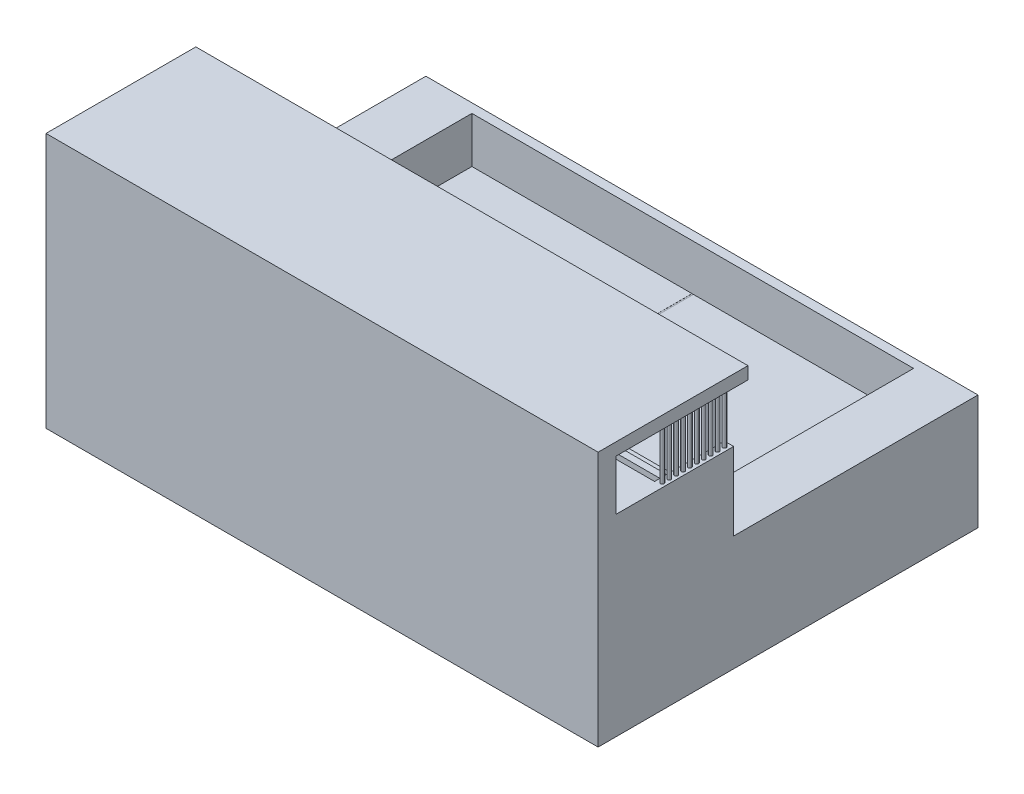
from build123d import *

# Parameters (mm, degrees)
SKETCH_1_W            = 100
SKETCH_1_H            = 50
EXTRUDE_1_DEPTH       = 200
SKETCH_2_W            = 192
SKETCH_2_H            = 92
CUT_EXTRUDE_1_DEPTH   = 20
SKETCH_3_W            = 100
SKETCH_3_H            = 50
EXTRUDE_2_DEPTH       = 20
SKETCH_4_W            = 100
SKETCH_4_H            = 50
EXTRUDE_3_DEPTH       = 20
SKETCH_6_W            = 23
SKETCH_6_H            = 10
CUT_EXTRUDE_2_DEPTH   = 15
SKETCH_7_W            = 23
SKETCH_7_H            = 10
CUT_EXTRUDE_3_DEPTH   = 15
SKETCH_10_R           = 21.643075995
SKETCH_10_R_2         = 21.043075995
SKETCH_10_W           = 0.6
SKETCH_10_H           = 92
CUT_EXTRUDE_2_2_DEPTH = 0.05
EXTRUDE_4_DEPTH       = 240
SKETCH_12_W           = 30.390175899
SKETCH_12_H           = 33.741429703
EXTRUDE_5_DEPTH       = 4
SKETCH_13_W           = 30.390175899
SKETCH_13_H           = 33.741429703
EXTRUDE_6_DEPTH       = 4
SKETCH_14_R           = 0.75
EXTRUDE_7_DEPTH       = 27.291157


with BuildPart() as part:
    # 草圖1 → 填料-伸長1 (new body)
    with BuildSketch(Plane(origin=(0, 0, 0), x_dir=(0, 0, -1), z_dir=(1, 0, 0))):
        Rectangle(SKETCH_1_W, SKETCH_1_H)
    extrude(amount=EXTRUDE_1_DEPTH)

    # 草圖2 → 除料-伸長1 (cut)
    with BuildSketch(Plane(origin=(0, 25, 0), x_dir=(1, 0, 0), z_dir=(0, 1, 0))):
        with Locations((100, 0)):
            Rectangle(SKETCH_2_W, SKETCH_2_H)
    extrude(amount=-CUT_EXTRUDE_1_DEPTH, mode=Mode.SUBTRACT)

    # 草圖3 → 填料-伸長2 (add)
    with BuildSketch(Plane.ZY):
        Rectangle(SKETCH_3_W, SKETCH_3_H)
    extrude(amount=EXTRUDE_2_DEPTH)

    # 草圖4 → 填料-伸長3 (add)
    with BuildSketch(Plane(origin=(200, 0, 0), x_dir=(0, 0, -1), z_dir=(1, 0, 0))):
        Rectangle(SKETCH_4_W, SKETCH_4_H)
    extrude(amount=EXTRUDE_3_DEPTH)

    # 草圖6 → Cut-Extrude 2 (cut)
    with BuildSketch(Plane(origin=(4, 0, 0), x_dir=(0, 0, -1), z_dir=(1, 0, 0))):
        with Locations((0, 10)):
            Rectangle(SKETCH_6_W, SKETCH_6_H)
    extrude(amount=-CUT_EXTRUDE_2_DEPTH, mode=Mode.SUBTRACT)

    # 草圖7 → 除料-伸長3 (cut)
    with BuildSketch(Plane.ZY.offset(-196)):
        with Locations((0, 10)):
            Rectangle(SKETCH_7_W, SKETCH_7_H)
    extrude(amount=-CUT_EXTRUDE_3_DEPTH, mode=Mode.SUBTRACT)

    # 草圖10 → Cut-Extrude 2 2 (cut)
    with BuildSketch(Plane(origin=(0, 5, 0), x_dir=(1, 0, 0), z_dir=(0, 1, 0))):
        with Locations((100, 0)):
            Circle(SKETCH_10_R)
        with Locations((100, 0)):
            Circle(SKETCH_10_R_2, mode=Mode.SUBTRACT)
        with Locations((100, 0)):
            Rectangle(SKETCH_10_W, SKETCH_10_H)
    extrude(amount=-CUT_EXTRUDE_2_2_DEPTH, mode=Mode.SUBTRACT)

    # 草圖11 → 填料-伸長4 (add)
    with BuildSketch(Plane(origin=(220, 0, 0), x_dir=(0, 0, -1), z_dir=(1, 0, 0))):
        Polygon((-50, 25), (-56.223345598, 25), (-56.223345598, 33.611091941), (-59.145477896, 33.611091941), (-59.145477896, 27.182400885), (-64.794933673, 27.182400885), (-64.794933673, 32.052621382), (-70.054771809, 32.052621382), (-70.054771809, 38.481312437), (-76.483462864, 38.481312437), (-76.483462864, 44.520385853), (-81.938109821, 44.520385853), (-81.938109821, 50.949076909), (-86.613521497, 50.949076909), (-86.613521497, 58.741429703), (-107.458065223, 58.741429703), (-107.458065223, 80.646512644), (-50, 80.646512644), (-50, 86.032586896), (-115.138208137, 86.032586896), (-115.138208137, -25), (-50, -25), align=None)
    extrude(amount=-EXTRUDE_4_DEPTH)

    # 草圖12 → 填料-伸長5 (add)
    with BuildSketch(Plane(origin=(220, 0, 0), x_dir=(0, 0, -1), z_dir=(1, 0, 0))):
        with Locations((-71.418433548, 41.870714851)):
            Rectangle(SKETCH_12_W, SKETCH_12_H)
    extrude(amount=-EXTRUDE_5_DEPTH)

    # 草圖13 → 填料-伸長6 (add)
    with BuildSketch(Plane.ZY.offset(20)):
        with Locations((71.418433548, 41.870714851)):
            Rectangle(SKETCH_13_W, SKETCH_13_H)
    extrude(amount=-EXTRUDE_6_DEPTH)

    # 草圖14 → 填料-伸長7 (add)
    with BuildSketch(Plane(origin=(0, 86.032586896, 0), x_dir=(1, 0, 0), z_dir=(0, 1, 0))):
        with Locations((218.161156155, -76.375011751)):
            Circle(SKETCH_14_R)
        with Locations((218.161156155, -73.375011751)):
            Circle(SKETCH_14_R)
        with Locations((218.161156155, -70.375011751)):
            Circle(SKETCH_14_R)
        with Locations((218.161156155, -67.375011751)):
            Circle(SKETCH_14_R)
        with Locations((218.161156155, -64.375011751)):
            Circle(SKETCH_14_R)
        with Locations((218.161156155, -61.375011751)):
            Circle(SKETCH_14_R)
        with Locations((218.161156155, -58.375011751)):
            Circle(SKETCH_14_R)
        with Locations((-18.761156155, -85.375011751)):
            Circle(SKETCH_14_R)
        with Locations((-18.761156155, -79.375011751)):
            Circle(SKETCH_14_R)
        with Locations((-18.761156155, -70.375011751)):
            Circle(SKETCH_14_R)
        with Locations((218.161156155, -85.375011751)):
            Circle(SKETCH_14_R)
        with Locations((218.161156155, -82.375011751)):
            Circle(SKETCH_14_R)
        with Locations((218.161156155, -79.375011751)):
            Circle(SKETCH_14_R)
        with Locations((-18.761156155, -82.375011751)):
            Circle(SKETCH_14_R)
        with Locations((-18.761156155, -76.375011751)):
            Circle(SKETCH_14_R)
        with Locations((-18.761156155, -73.375011751)):
            Circle(SKETCH_14_R)
        with Locations((-18.761156155, -67.375011751)):
            Circle(SKETCH_14_R)
        with Locations((-18.761156155, -64.375011751)):
            Circle(SKETCH_14_R)
    extrude(amount=-EXTRUDE_7_DEPTH)


solid = part.part
